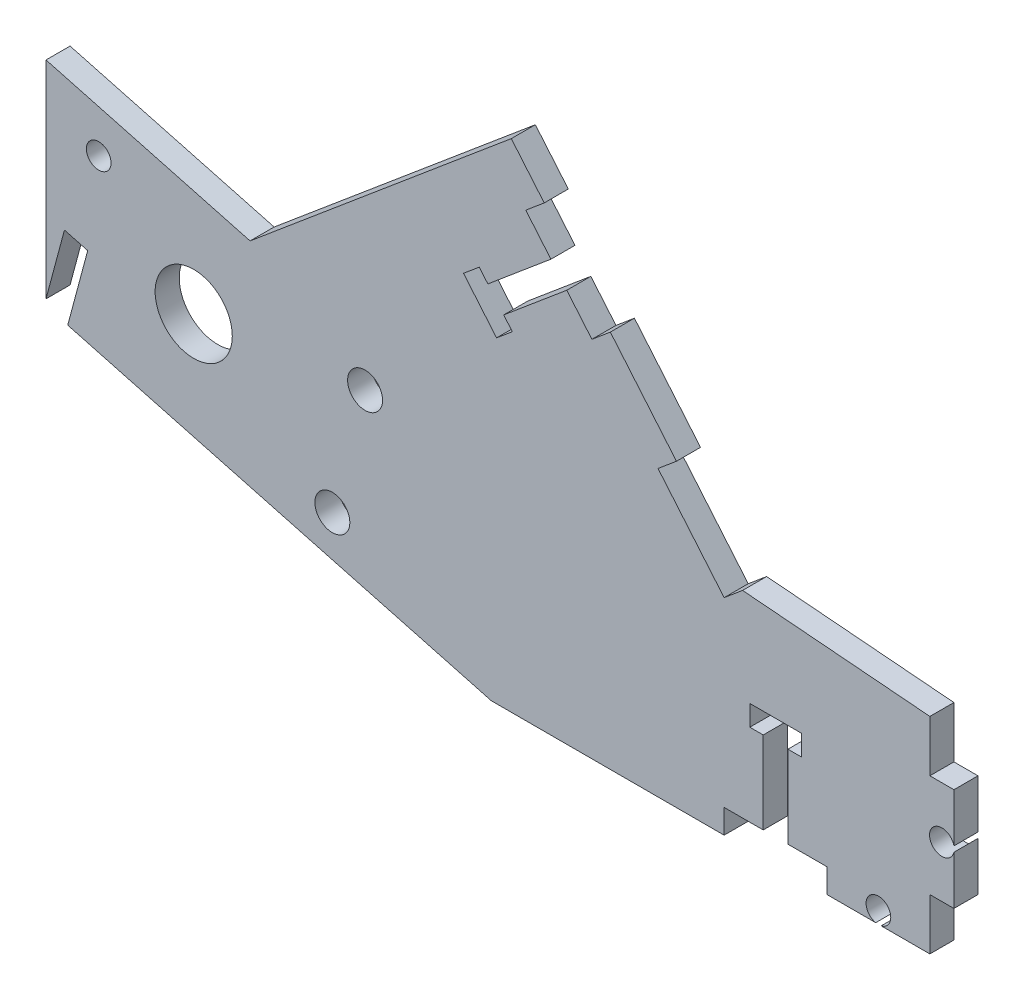
from build123d import *

# Parameters (mm, degrees)
SKETCH1_R           = 2.159
SKETCH1_R_2         = 4.7625
BOSS_EXTRUDE1_DEPTH = 2.9718
SKETCH2_R           = 1.524
CUT_EXTRUDE2_DEPTH  = 3.9718


with BuildPart() as part:
    # Sketch1 → Boss-Extrude1 (new body)
    with BuildSketch(Plane.XY):
        Polygon((-109.126324886, 41.028491651), (-109.126324886, 15.481473491), (-106.848322687, 23.983093437), (-103.977784316, 23.213934999), (-106.443035721, 14.013491503), (-54.143973439, 0), (-25.4, 0), (-25.4, 2.9718), (-12.7, 2.9718), (-12.7, 0), (0, 0), (0, 6.35), (2.9718, 6.35), (2.9718, 19.05), (0, 19.05), (0, 25.4), (-23.123469124, 27.310236218), (-25.4, 25.4), (-33.563402643, 35.128764428), (-31.286871767, 37.039000646), (-39.45027441, 46.767765074), (-41.726805286, 44.857528855), (-49.890207929, 54.586293283), (-47.613677053, 56.496529501), (-51.67877148, 61.341120389), (-83.931779224, 34.277633487), align=None)
        with Locations((-73.773359536, 10.321661037)):
            Circle(SKETCH1_R, mode=Mode.SUBTRACT)
        with Locations((-90.888775854, 22.993747625)):
            Circle(SKETCH1_R_2, mode=Mode.SUBTRACT)
        with Locations((-69.730347232, 25.410388369)):
            Circle(SKETCH1_R, mode=Mode.SUBTRACT)
    extrude(amount=BOSS_EXTRUDE1_DEPTH)

    # Sketch2 → Cut-Extrude2 (cut, through all)
    with BuildSketch(Plane.XY.offset(2.9718)):
        with Locations((1.4859, 12.7)):
            Circle(SKETCH2_R)
        with Locations((-6.35, 1.4859)):
            Circle(SKETCH2_R)
        with Locations((-102.61910191, 34.025683513)):
            Circle(SKETCH2_R)
        Polygon((-22.225, 15.6718), (-15.875, 15.6718), (-15.875, 13.1318), (-17.526, 13.1318), (-17.526, 2.9718), (-20.574, 2.9718), (-20.574, 13.1318), (-22.225, 13.1318), align=None)
        Polygon((-57.578121696, 43.990699533), (-53.496420374, 39.126317319), (-51.550667489, 40.758997848), (-52.611909832, 42.023737223), (-44.82889829, 48.554459338), (-46.788114925, 50.8893628), (-54.571126467, 44.358640686), (-55.63236881, 45.623380062), align=None)
    extrude(amount=-CUT_EXTRUDE2_DEPTH, mode=Mode.SUBTRACT)


solid = part.part
